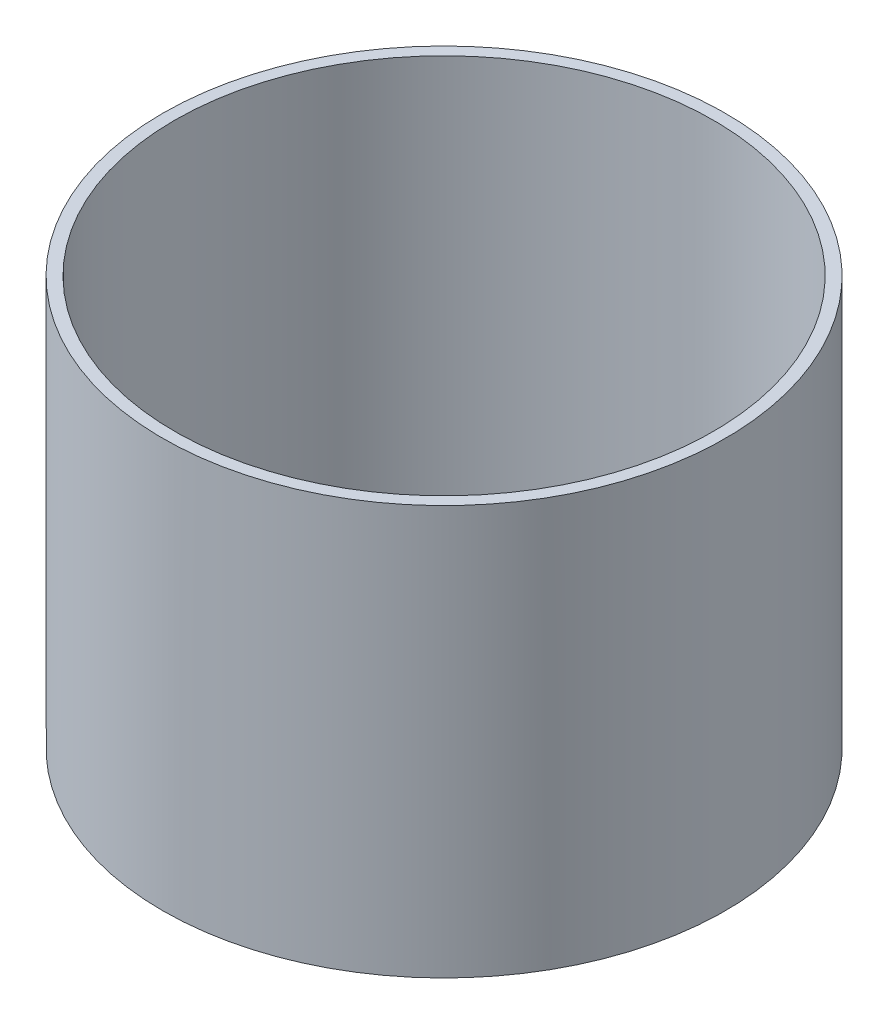
from build123d import *

# Parameters (mm, degrees)
SKETCH1_R           = 59.69
SKETCH1_R_2         = 57.15
BOSS_EXTRUDE1_DEPTH = 86.767161


with BuildPart() as part:
    # Sketch1 → Boss-Extrude1 (new body)
    with BuildSketch(Plane(origin=(0, 0, 0), x_dir=(1, 0, 0), z_dir=(0, 1, 0))):
        Circle(SKETCH1_R)
        Circle(SKETCH1_R_2, mode=Mode.SUBTRACT)
    extrude(amount=BOSS_EXTRUDE1_DEPTH)


solid = part.part
